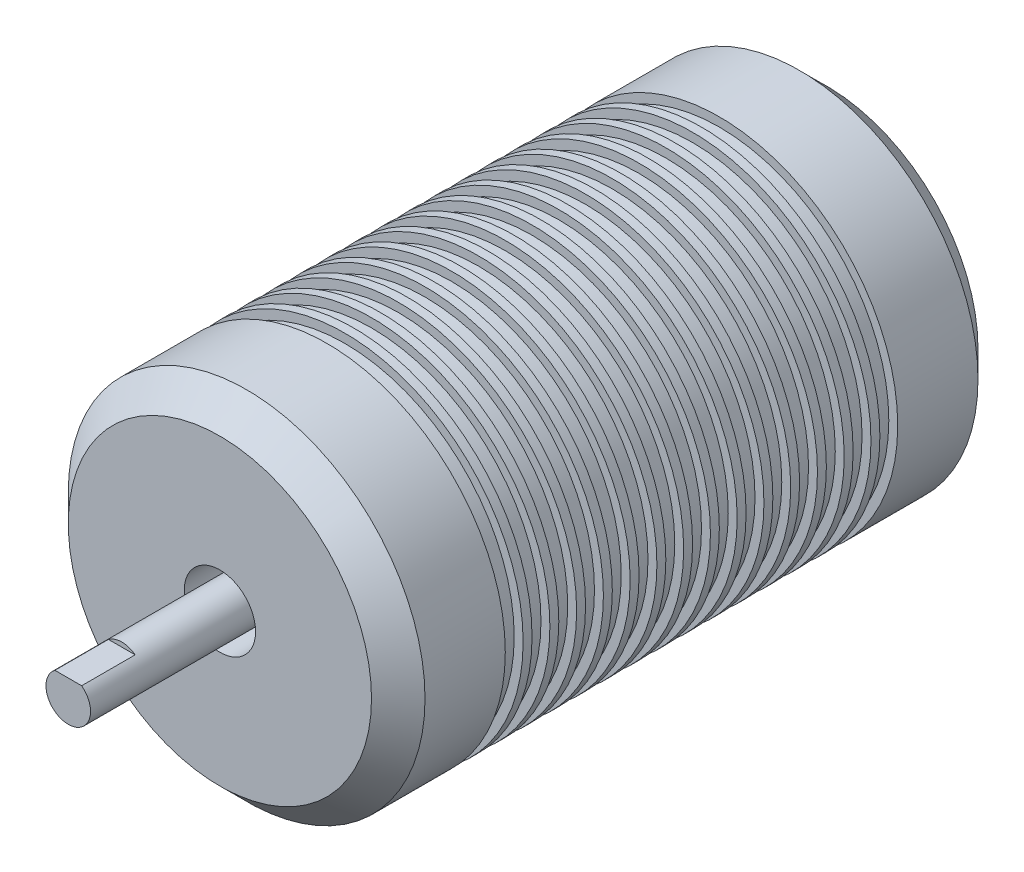
from build123d import *

# Parameters (mm, degrees)
SKETCH1_R           = 20
BOSS_EXTRUDE1_DEPTH = 68
SKETCH2_R           = 4
CUT_EXTRUDE1_DEPTH  = 10
SKETCH3_R           = 2.5
BOSS_EXTRUDE2_DEPTH = 27
CUT_EXTRUDE2_DEPTH  = 6
CHAMFER1_SIZE       = 3
CUT_EXTRUDE3_START  = -12
SKETCH5_R           = 20
SKETCH5_R_2         = 19
CUT_EXTRUDE3_DEPTH  = 2
LPATTERN1_COUNT     = 15
LPATTERN1_PITCH     = 3


with BuildPart() as part:
    # Sketch1 → Boss-Extrude1 (new body)
    with BuildSketch(Plane.XY):
        Circle(SKETCH1_R)
    extrude(amount=BOSS_EXTRUDE1_DEPTH)

    # Sketch2 → Cut-Extrude1 (cut)
    with BuildSketch(Plane.XY.offset(68)):
        Circle(SKETCH2_R)
    extrude(amount=-CUT_EXTRUDE1_DEPTH, mode=Mode.SUBTRACT)

    # Sketch3 → Boss-Extrude2 (add)
    with BuildSketch(Plane.XY.offset(58)):
        Circle(SKETCH3_R)
    extrude(amount=BOSS_EXTRUDE2_DEPTH)

    # Sketch4 → Cut-Extrude2 (cut)
    with BuildSketch(Plane.XY.offset(85)):
        Polygon((-73.022353661, 2), (-1.5, 2), (1.5, 2), (73.022353661, 2), (73.022353661, 145.044707322), (-73.022353661, 145.044707322), align=None)
    extrude(amount=-CUT_EXTRUDE2_DEPTH, mode=Mode.SUBTRACT)

    # Chamfer1
    chamfer1_edges = [part.edges().sort_by_distance(p)[0] for p in [
        (-20, 0, 0),
        (-20, 0, 68),
    ]]
    chamfer(chamfer1_edges, length=CHAMFER1_SIZE)

    # Sketch5 → Cut-Extrude3 (cut)
    with BuildSketch(Plane.XY.offset(68).offset(CUT_EXTRUDE3_START)):
        Circle(SKETCH5_R)
        Circle(SKETCH5_R_2, mode=Mode.SUBTRACT)
    cut_extrude3 = extrude(amount=-CUT_EXTRUDE3_DEPTH, mode=Mode.SUBTRACT)

    # LPattern1: Cut-Extrude3 ×15
    with Locations(*[(0, 0, -i * LPATTERN1_PITCH) for i in range(1, LPATTERN1_COUNT)]):
        add(cut_extrude3, mode=Mode.SUBTRACT)


solid = part.part
